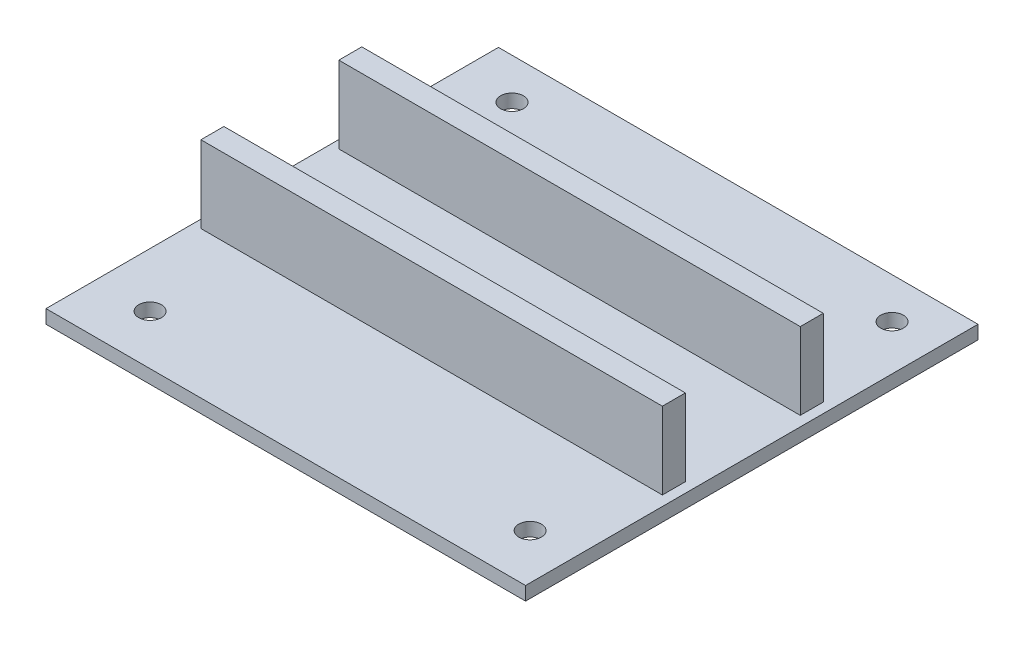
from build123d import *

# Parameters (mm, degrees)
SCHIZZO1_W                   = 53
SCHIZZO1_H                   = 50
ESTRUSIONE_ESTRUSIONE1_DEPTH = 1.5
SCHIZZO2_W                   = 51
SCHIZZO2_H                   = 2.54
ESTRUSIONE_ESTRUSIONE2_DEPTH = 8.5
SCHIZZO3_R                   = 1.25
TAGLIO_ESTRUSIONE1_DEPTH     = 8.5


with BuildPart() as part:
    # Schizzo1 → Estrusione-Estrusione1 (new body)
    with BuildSketch(Plane(origin=(0, 0, 0), x_dir=(1, 0, 0), z_dir=(0, 1, 0))):
        Rectangle(SCHIZZO1_W, SCHIZZO1_H)
    extrude(amount=ESTRUSIONE_ESTRUSIONE1_DEPTH)

    # Schizzo2 → Estrusione-Estrusione2 (add)
    with BuildSketch(Plane(origin=(0, 1.5, 0), x_dir=(1, 0, 0), z_dir=(0, 1, 0))):
        with Locations((-0.1, 7.73)):
            Rectangle(SCHIZZO2_W, SCHIZZO2_H)
        with Locations((-0.1, -7.51)):
            Rectangle(SCHIZZO2_W, SCHIZZO2_H)
    extrude(amount=ESTRUSIONE_ESTRUSIONE2_DEPTH)

    # Schizzo3 → Taglio-Estrusione1 (cut)
    with BuildSketch(Plane(origin=(0, 1.5, 0), x_dir=(1, 0, 0), z_dir=(0, 1, 0))):
        with Locations((21.5, 20.5)):
            Circle(SCHIZZO3_R)
        with Locations((-20.5, 20.5)):
            Circle(SCHIZZO3_R)
        with Locations((21.5, -19.5)):
            Circle(SCHIZZO3_R)
        with Locations((-20.5, -19.5)):
            Circle(SCHIZZO3_R)
    extrude(amount=-TAGLIO_ESTRUSIONE1_DEPTH, mode=Mode.SUBTRACT)


solid = part.part
